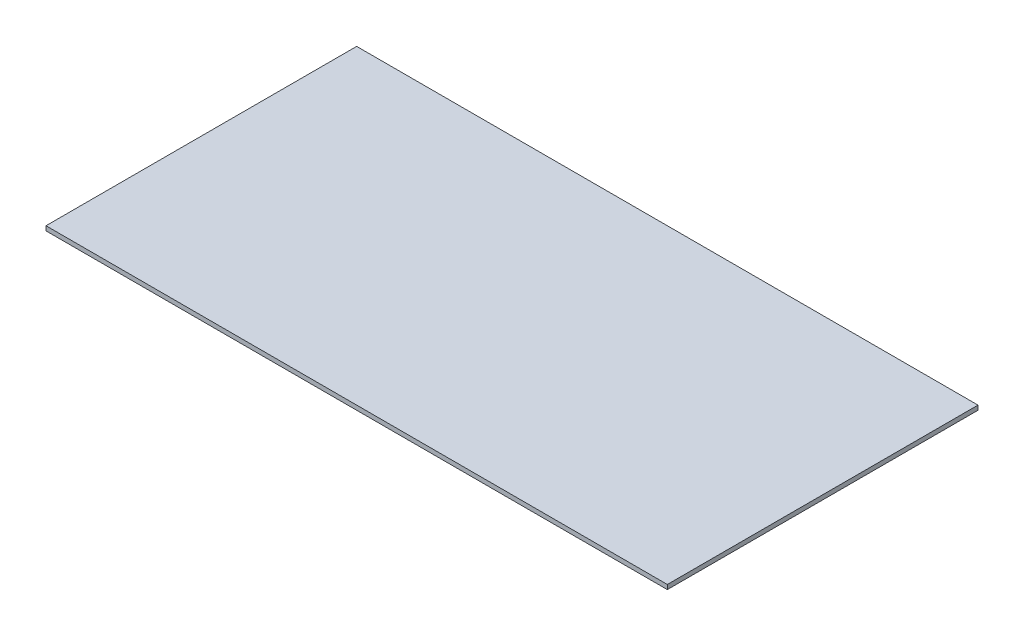
from build123d import *

# Parameters (mm, degrees)
SKETCH1_W           = 50
SKETCH1_H           = 25
BOSS_EXTRUDE1_DEPTH = 0.36


with BuildPart() as part:
    # Sketch1 → Boss-Extrude1 (new body)
    with BuildSketch(Plane(origin=(0, 0, 0), x_dir=(1, 0, 0), z_dir=(0, 1, 0))):
        with Locations((25, 12.5)):
            Rectangle(SKETCH1_W, SKETCH1_H)
    extrude(amount=BOSS_EXTRUDE1_DEPTH)


solid = part.part
